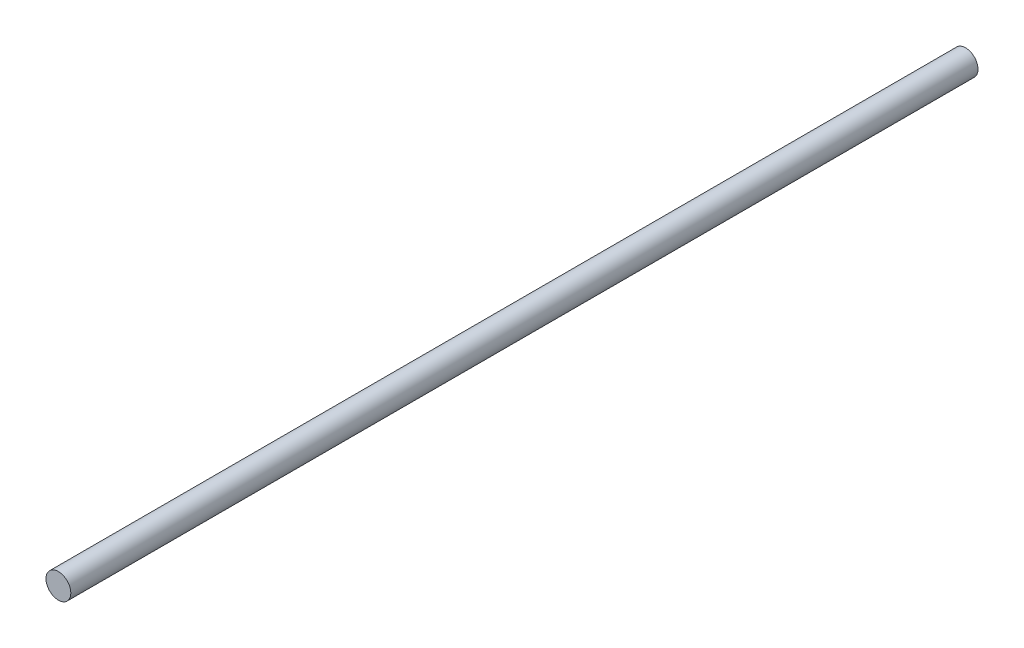
from build123d import *

# Parameters (mm, degrees)
SKETCH2_R           = 0.6604
BOSS_EXTRUDE1_DEPTH = 48.26


with BuildPart() as part:
    # Sketch2 → Boss-Extrude1 (new body)
    with BuildSketch(Plane.XY):
        Circle(SKETCH2_R)
    extrude(amount=BOSS_EXTRUDE1_DEPTH)


solid = part.part
